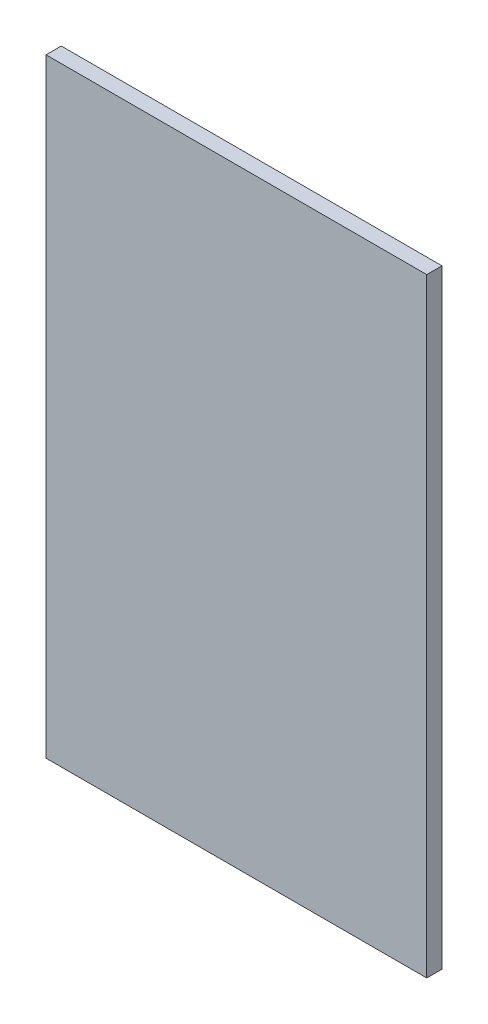
from build123d import *

# Parameters (mm, degrees)
CROQUIS1_W              = 50
CROQUIS1_H              = 80
SALIENTE_EXTRUIR1_DEPTH = 2


with BuildPart() as part:
    # Croquis1 → Saliente-Extruir1 (new body)
    with BuildSketch(Plane.XY):
        Rectangle(CROQUIS1_W, CROQUIS1_H)
    extrude(amount=SALIENTE_EXTRUIR1_DEPTH)


solid = part.part
